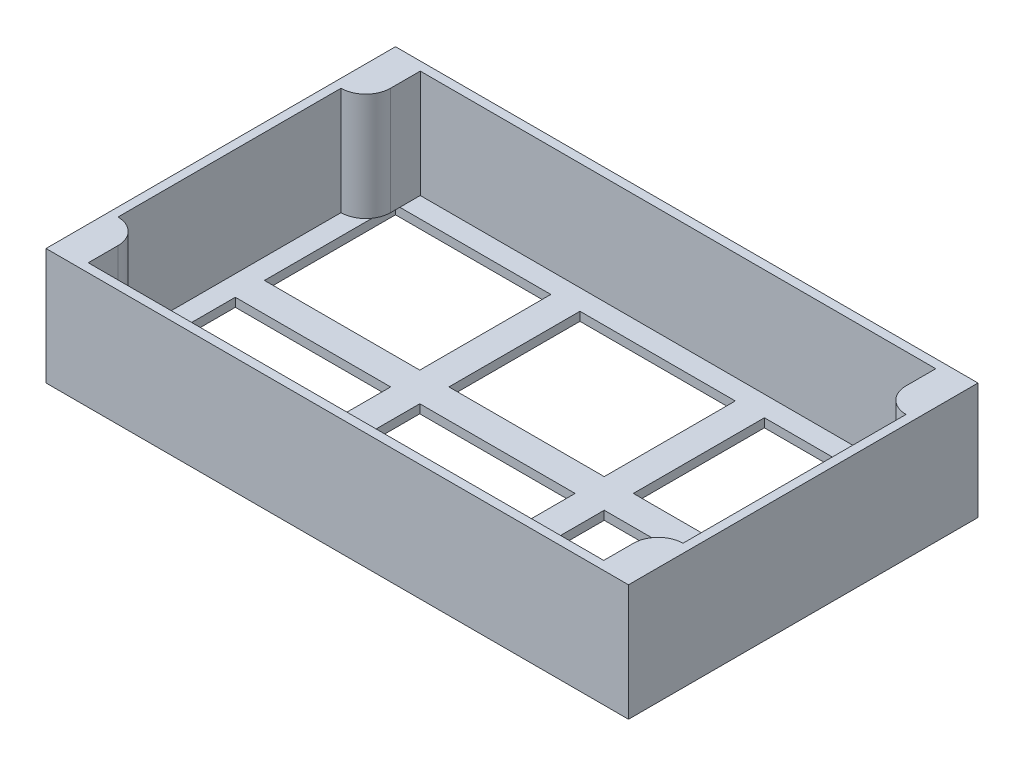
from build123d import *

# Parameters (mm, degrees)
SKETCH1_W           = 200
SKETCH1_H           = 120
SKETCH1_W_2         = 53.333333333
SKETCH1_H_2         = 45
SKETCH1_W_3         = 53.333333334
BOSS_EXTRUDE1_DEPTH = 3
SKETCH2_W           = 200
SKETCH2_H           = 120
BOSS_EXTRUDE2_DEPTH = 37


with BuildPart() as part:
    # Sketch1 → Boss-Extrude1 (new body)
    with BuildSketch(Plane(origin=(0, 0, 0), x_dir=(1, 0, 0), z_dir=(0, 1, 0))):
        with Locations((100, 60)):
            Rectangle(SKETCH1_W, SKETCH1_H)
        with Locations((36.666666667, 87.5)):
            Rectangle(SKETCH1_W_2, SKETCH1_H_2, mode=Mode.SUBTRACT)
        with Locations((36.666666667, 32.5)):
            Rectangle(SKETCH1_W_2, SKETCH1_H_2, mode=Mode.SUBTRACT)
        with Locations((100, 87.5)):
            Rectangle(SKETCH1_W_3, SKETCH1_H_2, mode=Mode.SUBTRACT)
        with Locations((163.333333334, 87.5)):
            Rectangle(SKETCH1_W_2, SKETCH1_H_2, mode=Mode.SUBTRACT)
        with Locations((163.333333334, 32.5)):
            Rectangle(SKETCH1_W_2, SKETCH1_H_2, mode=Mode.SUBTRACT)
        with Locations((100, 32.5)):
            Rectangle(SKETCH1_W_3, SKETCH1_H_2, mode=Mode.SUBTRACT)
    extrude(amount=BOSS_EXTRUDE1_DEPTH)

    # Sketch2 → Boss-Extrude2 (add)
    with BuildSketch(Plane(origin=(0, 3, 0), x_dir=(1, 0, 0), z_dir=(0, 1, 0))):
        with Locations((100, 60)):
            Rectangle(SKETCH2_W, SKETCH2_H)
        with BuildLine():
            Line((3, 98.3), (3, 21.7))
            ThreePointArc((3, 21.7), (9.01040764, 19.21040764), (11.5, 13.2))
            Line((11.5, 13.2), (11.5, 3))
            Line((11.5, 3), (188.5, 3))
            Line((188.5, 3), (188.5, 13.2))
            ThreePointArc((188.5, 13.2), (190.98959236, 19.21040764), (197, 21.7))
            Line((197, 21.7), (197, 98.3))
            ThreePointArc((197, 98.3), (190.98959236, 100.78959236), (188.5, 106.8))
            Line((188.5, 106.8), (188.5, 117))
            Line((188.5, 117), (11.5, 117))
            Line((11.5, 117), (11.5, 106.8))
            ThreePointArc((11.5, 106.8), (9.01040764, 100.78959236), (3, 98.3))
        make_face(mode=Mode.SUBTRACT)
    extrude(amount=BOSS_EXTRUDE2_DEPTH)


solid = part.part
